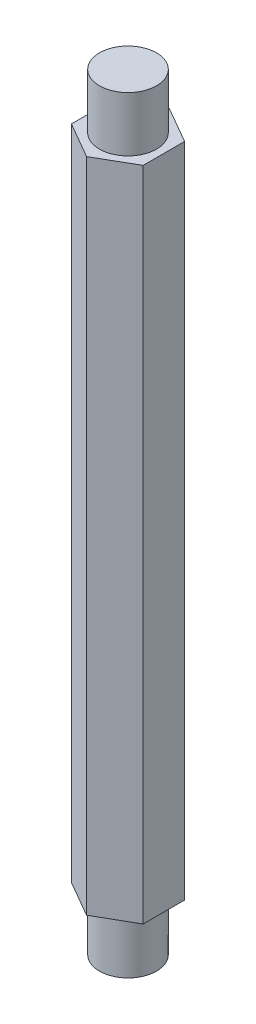
from build123d import *

# Parameters (mm, degrees)
SKETCH1_R           = 1.65
BOSS_EXTRUDE1_DEPTH = 38
SKETCH2_R           = 1.65
BOSS_EXTRUDE2_DEPTH = 3.175
SKETCH3_R           = 1.65
BOSS_EXTRUDE3_DEPTH = 3.175


with BuildPart() as part:
    # Sketch1 → Boss-Extrude1 (new body)
    with BuildSketch(Plane(origin=(0, 0, 0), x_dir=(1, 0, 0), z_dir=(0, 1, 0))):
        Polygon((0, -2.396003617), (2.075, -1.198001809), (2.075, 1.198001809), (0, 2.396003617), (-2.075, 1.198001809), (-2.075, -1.198001809), align=None)
        Circle(SKETCH1_R, mode=Mode.SUBTRACT)
    extrude(amount=BOSS_EXTRUDE1_DEPTH)


with BuildPart() as body_2:
    # Sketch2 → Boss-Extrude2 (new body)
    with BuildSketch(Plane.XZ):
        Circle(SKETCH2_R)
    extrude(amount=BOSS_EXTRUDE2_DEPTH)


with BuildPart() as body_3:
    # Sketch3 → Boss-Extrude3 (new body)
    with BuildSketch(Plane(origin=(0, 38, 0), x_dir=(1, 0, 0), z_dir=(0, 1, 0))):
        Circle(SKETCH3_R)
    extrude(amount=BOSS_EXTRUDE3_DEPTH)


solid = Compound([part.part, body_2.part, body_3.part])
